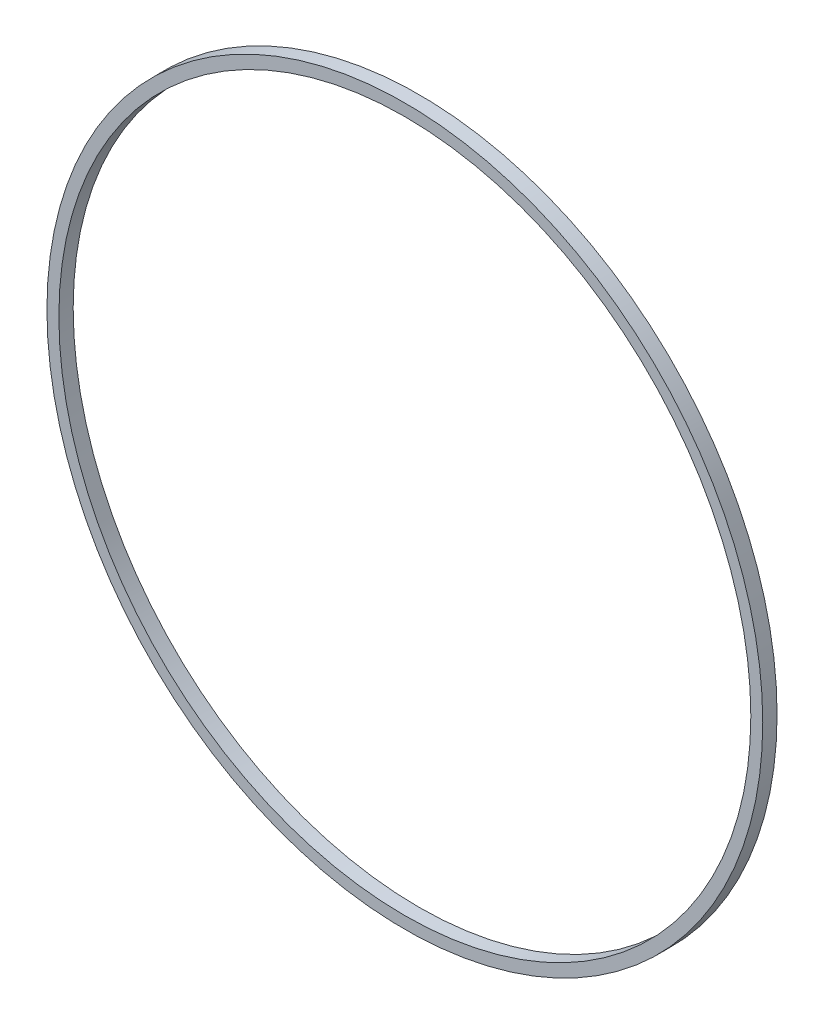
from build123d import *

# Parameters (mm, degrees)
SKIZZE1_R                       = 30
SKIZZE1_R_2                     = 29
AUFSATZ_LINEAR_AUSTRAGEN1_DEPTH = 1.2


with BuildPart() as part:
    # Skizze1 → Aufsatz-Linear austragen1 (new body)
    with BuildSketch(Plane.XY):
        with Locations((-11.826910792, 13.522907101)):
            Circle(SKIZZE1_R)
        with Locations((-11.826910792, 13.522907101)):
            Circle(SKIZZE1_R_2, mode=Mode.SUBTRACT)
    extrude(amount=AUFSATZ_LINEAR_AUSTRAGEN1_DEPTH)


solid = part.part
